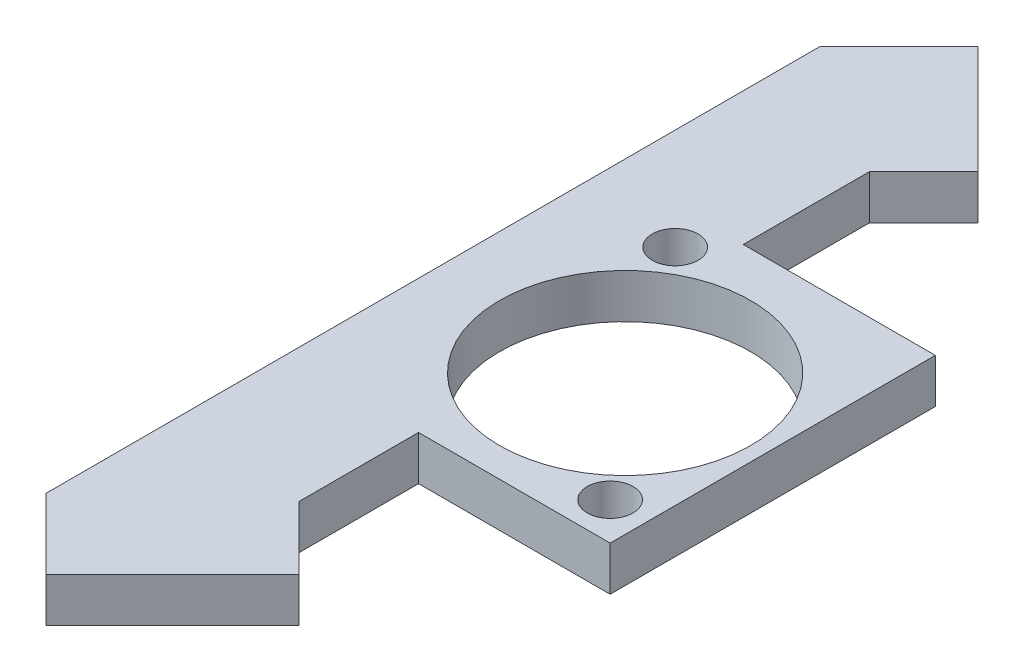
from build123d import *

# Parameters (mm, degrees)
SKETCH1_W           = 22
SKETCH1_H           = 22
SKETCH1_R           = 1.55
SKETCH1_R_2         = 8.5
BOSS_EXTRUDE1_DEPTH = 3
BOSS_EXTRUDE2_DEPTH = 3


with BuildPart() as part:
    # Sketch1 → Boss-Extrude1 (new body)
    with BuildSketch(Plane(origin=(0, 0, 0), x_dir=(1, 0, 0), z_dir=(0, 1, 0))):
        with Locations((-27.765585807, 11.176708998)):
            Rectangle(SKETCH1_W, SKETCH1_H)
        with Locations((-19.305585807, 2.716708998)):
            Circle(SKETCH1_R, mode=Mode.SUBTRACT)
        with Locations((-31.905585807, 19.716708998)):
            Circle(SKETCH1_R, mode=Mode.SUBTRACT)
        with Locations((-26.223701498, 10.648645815)):
            Circle(SKETCH1_R_2, mode=Mode.SUBTRACT)
    extrude(amount=BOSS_EXTRUDE1_DEPTH)

    # Sketch2 → Boss-Extrude2 (add)
    with BuildSketch(Plane(origin=(0, 3, 0), x_dir=(1, 0, 0), z_dir=(0, 1, 0))):
        Polygon((-38.765585807, 0.176708998), (-38.765585807, -15.991830681), (-34.011681836, -20.745734651), (-25.445380771, -12.179433585), (-29.728531303, -7.896283053), (-29.728531303, 0.176708998), align=None)
        Polygon((-38.765585807, 22.176708998), (-38.765585807, 36.389702532), (-33.427082463, 41.728205876), (-26.085708647, 34.38683206), (-29.756395555, 30.716145153), (-29.756395555, 22.176708998), align=None)
    extrude(amount=-BOSS_EXTRUDE2_DEPTH)


solid = part.part
